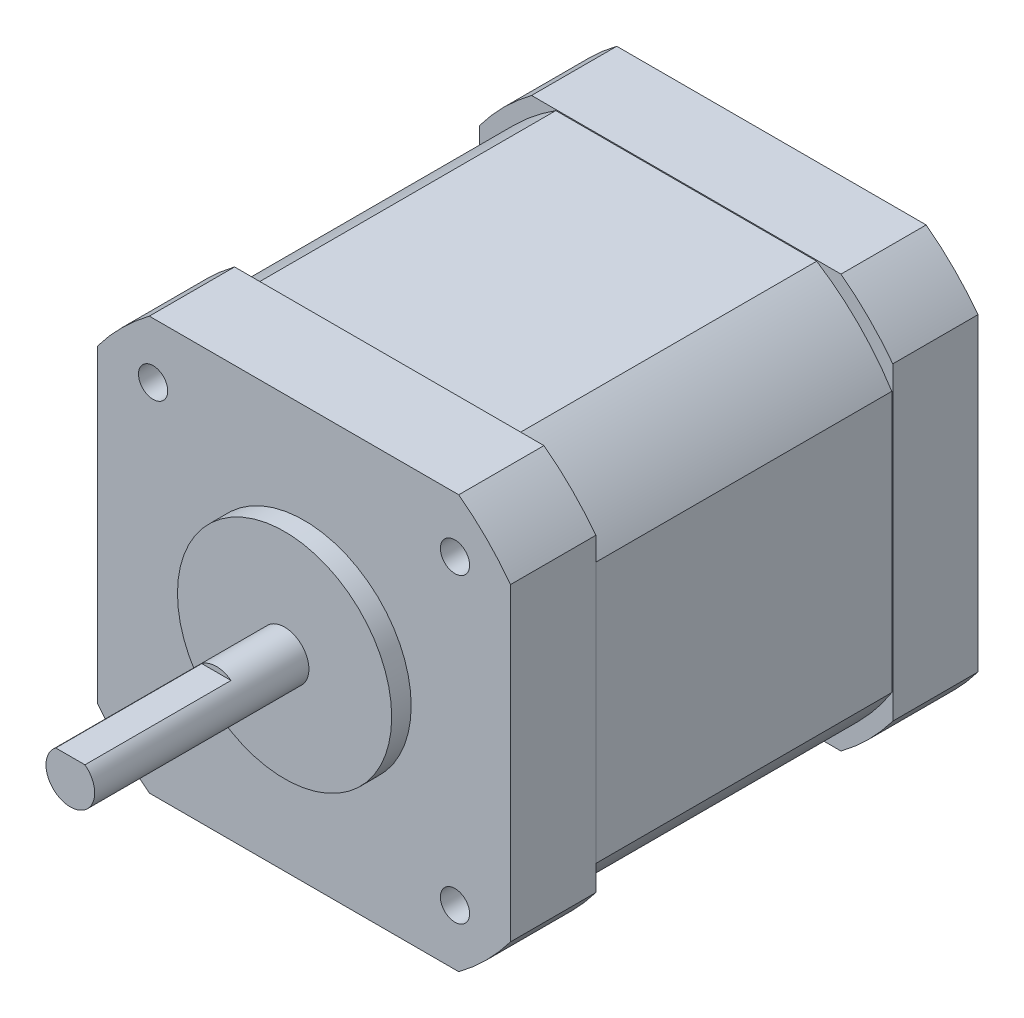
from build123d import *

# Parameters (mm, degrees)
SKETCH1_R                      = 2.5
BOSS_EXTRUDE1_DEPTH            = 24
SKETCH2_R                      = 11
BOSS_EXTRUDE2_DEPTH            = 2
SKETCH3_W                      = 42.418
SKETCH3_H                      = 42.418
BOSS_EXTRUDE3_DEPTH            = 48
CUT_EXTRUDE1_DEPTH             = 73
M3X0_5_TAPPED_HOLE1_AT_2_COUNT = 2
M3X0_5_TAPPED_HOLE1_AT_2_PITCH = 31
M3X0_5_TAPPED_HOLE1_AT_3_COUNT = 2
M3X0_5_TAPPED_HOLE1_AT_3_PITCH = 43.840620434
M3X0_5_TAPPED_HOLE1_AT_4_COUNT = 2
M3X0_5_TAPPED_HOLE1_AT_4_PITCH = 31
CUT_EXTRUDE2_DEPTH             = 15
CUT_EXTRUDE3_DEPTH             = 15.25
CUT_EXTRUDE3_DEPTH_BACK        = 15.25


with BuildPart() as part:
    # Sketch1 → Boss-Extrude1 (new body)
    with BuildSketch(Plane.XY):
        Circle(SKETCH1_R)
    extrude(amount=BOSS_EXTRUDE1_DEPTH)

    # Sketch2 → Boss-Extrude2 (add)
    with BuildSketch(Plane(origin=(0, 0, 0), x_dir=(-1, 0, 0), z_dir=(0, 0, -1))):
        Circle(SKETCH2_R)
    extrude(amount=-BOSS_EXTRUDE2_DEPTH)

    # Sketch3 → Boss-Extrude3 (add)
    with BuildSketch(Plane(origin=(0, 0, 0), x_dir=(-1, 0, 0), z_dir=(0, 0, -1))):
        Rectangle(SKETCH3_W, SKETCH3_H)
    extrude(amount=BOSS_EXTRUDE3_DEPTH)

    # Sketch4 → Cut-Extrude1 (cut, through all)
    with BuildSketch(Plane(origin=(0, 0, -48), x_dir=(-1, 0, 0), z_dir=(0, 0, -1))):
        with BuildLine():
            Line((-21.209, -15.887992919), (-21.209, -21.209))
            Line((-21.209, -21.209), (-15.887992919, -21.209))
            ThreePointArc((-15.887992919, -21.209), (-18.738329701, -18.738329701), (-21.209, -15.887992919))
        make_face()
        with BuildLine():
            Line((15.887992919, -21.209), (21.209, -21.209))
            Line((21.209, -21.209), (21.209, -15.887992919))
            ThreePointArc((21.209, -15.887992919), (18.738329701, -18.738329701), (15.887992919, -21.209))
        make_face()
        with BuildLine():
            Line((21.209, 15.887992919), (21.209, 21.209))
            Line((21.209, 21.209), (15.887992919, 21.209))
            ThreePointArc((15.887992919, 21.209), (18.738329701, 18.738329701), (21.209, 15.887992919))
        make_face()
        with BuildLine():
            Line((-15.887992919, 21.209), (-21.209, 21.209))
            Line((-21.209, 21.209), (-21.209, 15.887992919))
            ThreePointArc((-21.209, 15.887992919), (-18.738329701, 18.738329701), (-15.887992919, 21.209))
        make_face()
    extrude(amount=-CUT_EXTRUDE1_DEPTH, mode=Mode.SUBTRACT)

    # Sketch5 → M3x0.5 Tapped Hole1 (revolve, cut)
    with BuildSketch(Plane(origin=(-15.5, 15.5, 0), x_dir=(0, -1, 0), z_dir=(1, 0, 0))):
        Polygon((0, 0), (0, 5.251075774), (1.25, 4.5), (1.25, 6), (1.5, 6), (1.5, 0), align=None)
    m3x0_5_tapped_hole1 = revolve(axis=Axis((-15.5, 15.5, 6.35), (0, 0, -1)), mode=Mode.SUBTRACT)

    # M3x0.5 Tapped Hole1 at 2: M3x0.5 Tapped Hole1 ×2
    with Locations(*[(0, -i * M3X0_5_TAPPED_HOLE1_AT_2_PITCH, 0) for i in range(1, M3X0_5_TAPPED_HOLE1_AT_2_COUNT)]):
        add(m3x0_5_tapped_hole1, mode=Mode.SUBTRACT)

    # M3x0.5 Tapped Hole1 at 3: M3x0.5 Tapped Hole1 ×2
    with Locations(*[Vector(0.707106781, -0.707106781, 0) * (i * M3X0_5_TAPPED_HOLE1_AT_3_PITCH) for i in range(1, M3X0_5_TAPPED_HOLE1_AT_3_COUNT)]):
        add(m3x0_5_tapped_hole1, mode=Mode.SUBTRACT)

    # M3x0.5 Tapped Hole1 at 4: M3x0.5 Tapped Hole1 ×2
    with Locations(*[(i * M3X0_5_TAPPED_HOLE1_AT_4_PITCH, 0, 0) for i in range(1, M3X0_5_TAPPED_HOLE1_AT_4_COUNT)]):
        add(m3x0_5_tapped_hole1, mode=Mode.SUBTRACT)

    # Sketch7 → Cut-Extrude2 (cut)
    with BuildSketch(Plane.XY.offset(24)):
        with BuildLine():
            Line((-1.5, 2), (1.5, 2))
            ThreePointArc((1.5, 2), (0, 2.5), (-1.5, 2))
        make_face()
    extrude(amount=-CUT_EXTRUDE2_DEPTH, mode=Mode.SUBTRACT)

    # Sketch8 → Cut-Extrude3 (cut, two sides)
    with BuildSketch(Plane.XY.offset(-24)) as cut_extrude3_sk:
        with BuildLine():
            Line((15.887992919, 21.209), (-15.887992919, 21.209))
            ThreePointArc((-15.887992919, 21.209), (-18.738329701, 18.738329701), (-21.209, 15.887992919))
            Line((-21.209, 15.887992919), (-21.209, -15.887992919))
            ThreePointArc((-21.209, -15.887992919), (-18.738329701, -18.738329701), (-15.887992919, -21.209))
            Line((-15.887992919, -21.209), (15.887992919, -21.209))
            ThreePointArc((15.887992919, -21.209), (18.738329701, -18.738329701), (21.209, -15.887992919))
            Line((21.209, -15.887992919), (21.209, 15.887992919))
            ThreePointArc((21.209, 15.887992919), (18.738329701, 18.738329701), (15.887992919, 21.209))
        make_face()
        with BuildLine():
            Line((-13.394406258, 21.109), (13.394406258, 21.109))
            ThreePointArc((13.394406258, 21.109), (17.67766953, 17.67766953), (21.109, 13.394406258))
            Line((21.109, 13.394406258), (21.109, -13.394406258))
            ThreePointArc((21.109, -13.394406258), (17.67766953, -17.67766953), (13.394406258, -21.109))
            Line((13.394406258, -21.109), (-13.394406258, -21.109))
            ThreePointArc((-13.394406258, -21.109), (-17.67766953, -17.67766953), (-21.109, -13.394406258))
            Line((-21.109, -13.394406258), (-21.109, 13.394406258))
            ThreePointArc((-21.109, 13.394406258), (-17.67766953, 17.67766953), (-13.394406258, 21.109))
        make_face(mode=Mode.SUBTRACT)
    extrude(amount=CUT_EXTRUDE3_DEPTH, mode=Mode.SUBTRACT)
    extrude(cut_extrude3_sk.sketch, amount=-CUT_EXTRUDE3_DEPTH_BACK, mode=Mode.SUBTRACT)


solid = part.part
